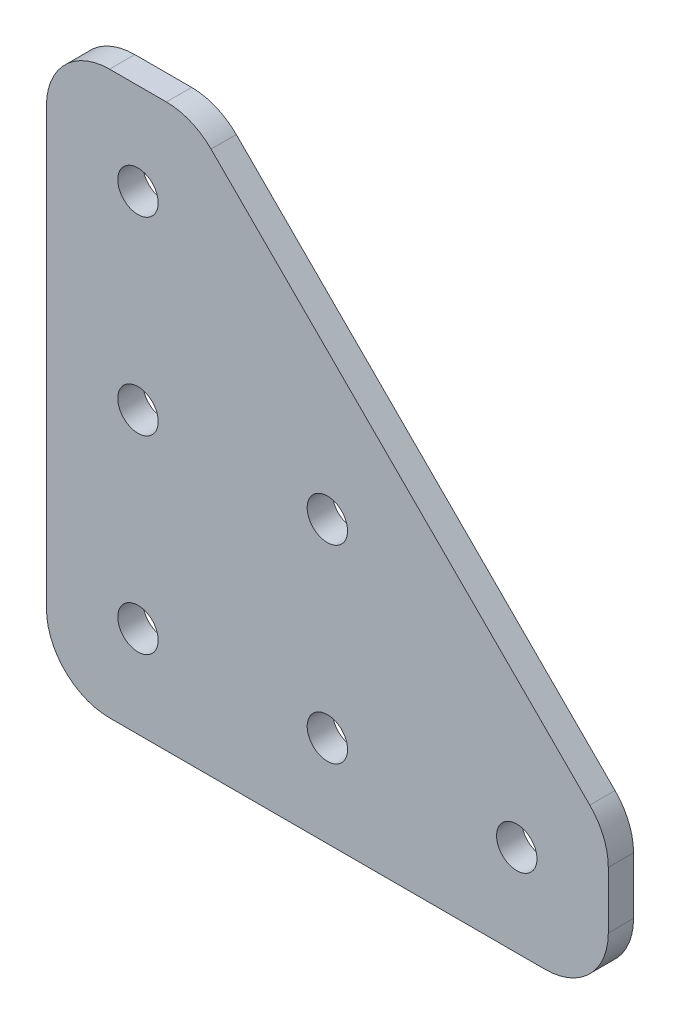
from build123d import *

# Parameters (mm, degrees)
SKETCH1_R           = 1.6
BOSS_EXTRUDE1_DEPTH = 2


with BuildPart() as part:
    # Sketch1 → Boss-Extrude1 (new body)
    with BuildSketch(Plane.XY):
        with BuildLine():
            Line((13.035533906, 43.035533906), (43.035533906, 13.035533906))
            ThreePointArc((43.035533906, 13.035533906), (44.119397663, 11.413417162), (44.5, 9.5))
            Line((44.5, 9.5), (44.5, 5))
            ThreePointArc((44.5, 5), (43.035533906, 1.464466094), (39.5, 0))
            Line((39.5, 0), (5, 0))
            ThreePointArc((5, 0), (1.464466094, 1.464466094), (0, 5))
            Line((0, 5), (0, 39.5))
            ThreePointArc((0, 39.5), (1.464466094, 43.035533906), (5, 44.5))
            Line((5, 44.5), (9.5, 44.5))
            ThreePointArc((9.5, 44.5), (11.413417162, 44.119397663), (13.035533906, 43.035533906))
        make_face()
        with Locations((7.25, 7.25)):
            Circle(SKETCH1_R, mode=Mode.SUBTRACT)
        with Locations((7.25, 22.25)):
            Circle(SKETCH1_R, mode=Mode.SUBTRACT)
        with Locations((7.25, 37.25)):
            Circle(SKETCH1_R, mode=Mode.SUBTRACT)
        with Locations((22.25, 7.25)):
            Circle(SKETCH1_R, mode=Mode.SUBTRACT)
        with Locations((37.25, 7.25)):
            Circle(SKETCH1_R, mode=Mode.SUBTRACT)
        with Locations((22.25, 22.25)):
            Circle(SKETCH1_R, mode=Mode.SUBTRACT)
    extrude(amount=BOSS_EXTRUDE1_DEPTH)


solid = part.part
